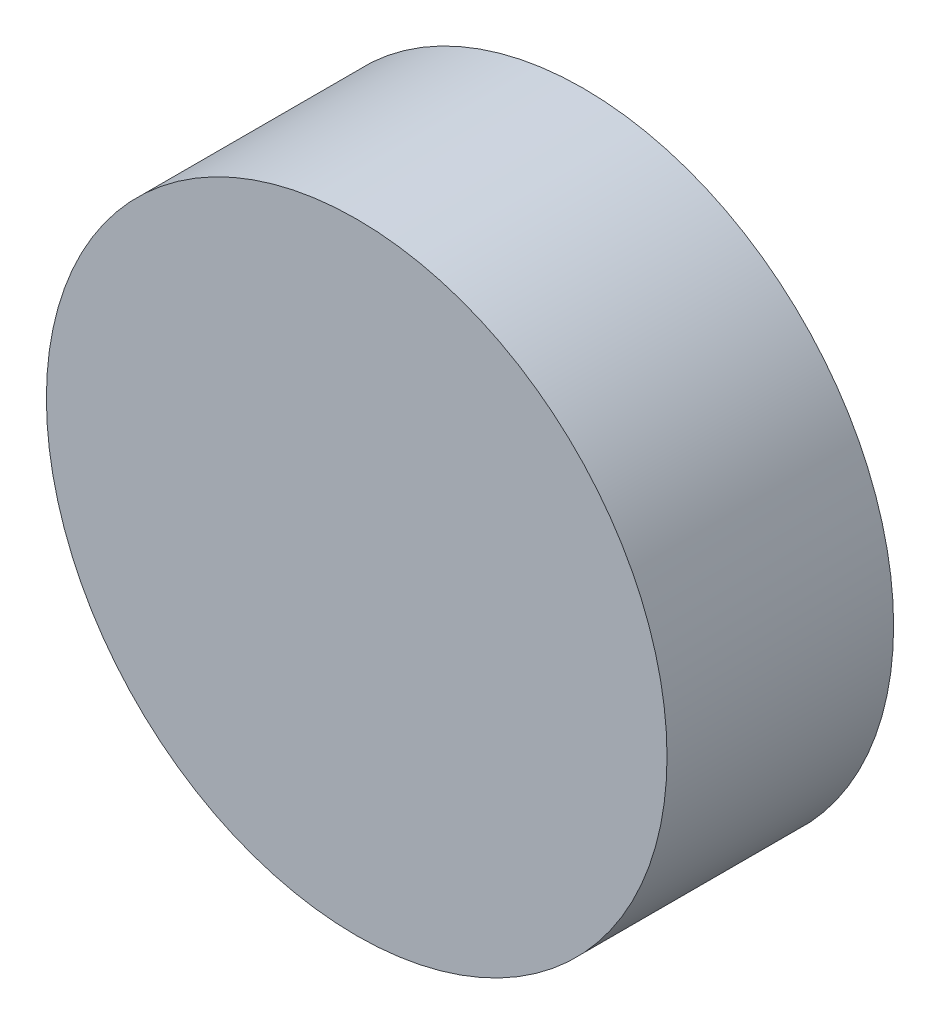
from build123d import *

# Parameters (mm, degrees)
SKETCH_1_R      = 3.15
EXTRUDE_1_DEPTH = 2.3


with BuildPart() as part:
    # 草图1 → 凸台-拉伸1 (new body)
    with BuildSketch(Plane.XY):
        with Locations((20.249587155, 12.312648367)):
            Circle(SKETCH_1_R)
    extrude(amount=EXTRUDE_1_DEPTH)


solid = part.part
